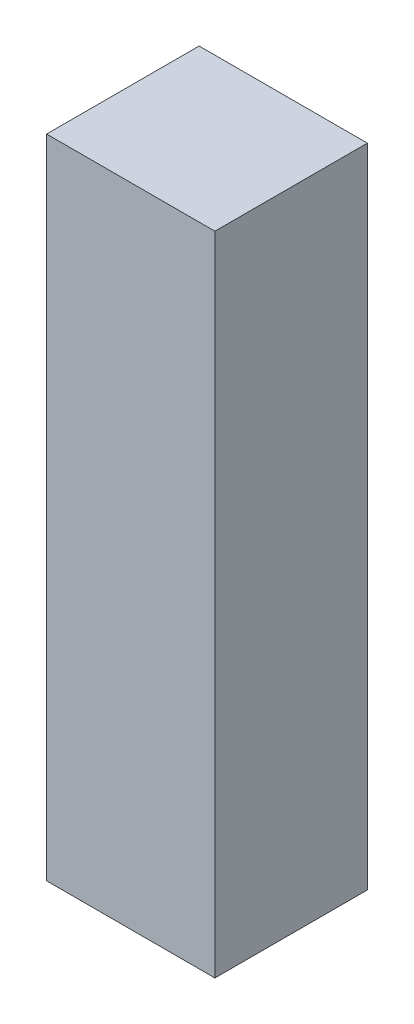
from build123d import *

# Parameters (mm, degrees)
SKETCH2_W           = 62.484
SKETCH2_H           = 16.256
BOSS_EXTRUDE1_DEPTH = 14.732


with BuildPart() as part:
    # Sketch2 → Boss-Extrude1 (new body)
    with BuildSketch(Plane(origin=(0, 0, 0), x_dir=(0, 1, 0), z_dir=(0, 0, 1))):
        Rectangle(SKETCH2_W, SKETCH2_H)
    extrude(amount=BOSS_EXTRUDE1_DEPTH)


solid = part.part
